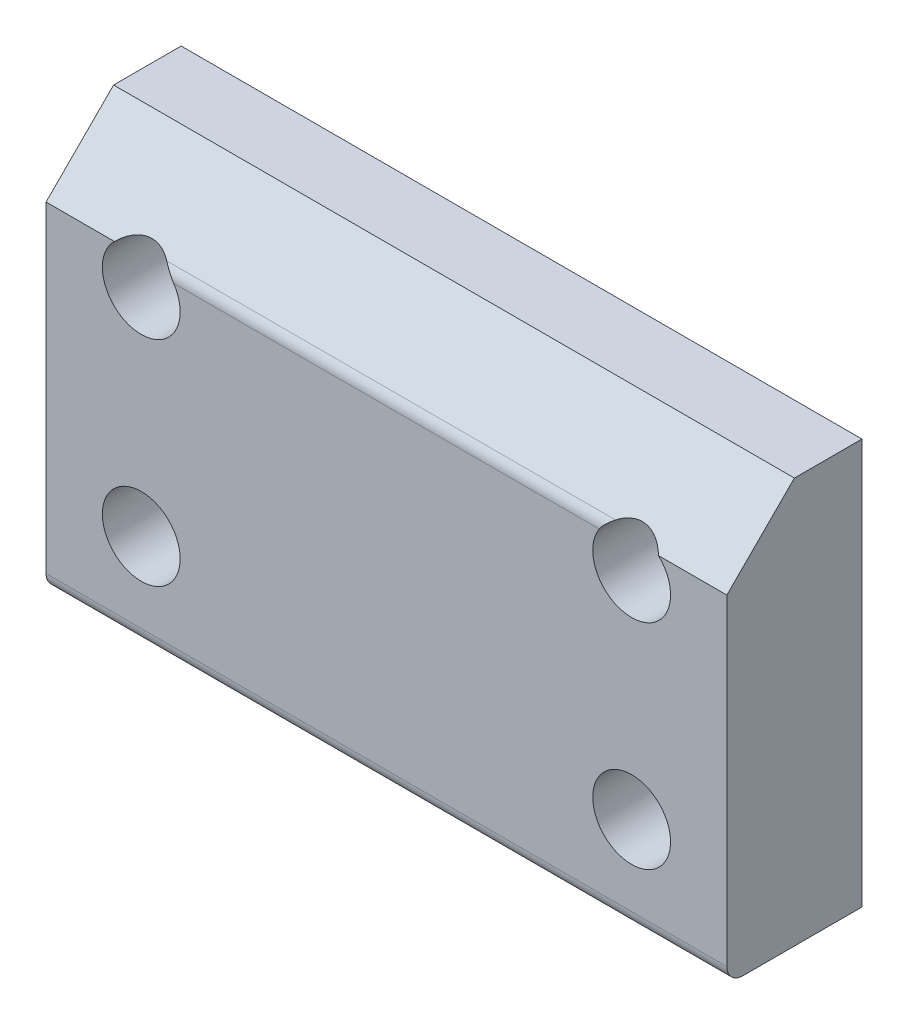
from build123d import *

# Parameters (mm, degrees)
BOSS_EXTRUDE1_DEPTH                            = 16
CBORE_FOR_6_SOCKET_HEAD_CAP_SCREW1_D           = 3.6576
CBORE_FOR_6_SOCKET_HEAD_CAP_SCREW1_DEPTH       = 9.398
CBORE_FOR_6_SOCKET_HEAD_CAP_SCREW1_CBORE_D     = 7.14502
CBORE_FOR_6_SOCKET_HEAD_CAP_SCREW1_CBORE_DEPTH = 2.54
CBORE_FOR_6_SOCKET_HEAD_CAP_SCREW1_TIP         = 1.0988539
FILLET1_R                                      = 0.75


with BuildPart() as part:
    # Sketch1 → Boss-Extrude1 (new, symmetric)
    with BuildSketch(Plane(origin=(0, 0, 0), x_dir=(0, 0, -1), z_dir=(1, 0, 0))):
        Polygon((0, 6.35), (3.175, 9.525), (6.35, 9.525), (6.35, -9.525), (0, -9.525), align=None)
    extrude(amount=BOSS_EXTRUDE1_DEPTH, both=True)

    # CBORE for _6 Socket Head Cap Screw1
    with Locations(Plane(origin=(0, 0, -6.35), x_dir=(-1, 0, 0), z_dir=(0, 0, -1))):
        with Locations((11.525, -5.025), (-11.525, 5.025), (-11.525, -5.025), (11.525, 5.025)):
            CounterBoreHole(CBORE_FOR_6_SOCKET_HEAD_CAP_SCREW1_D / 2, CBORE_FOR_6_SOCKET_HEAD_CAP_SCREW1_CBORE_D / 2, CBORE_FOR_6_SOCKET_HEAD_CAP_SCREW1_CBORE_DEPTH, depth=CBORE_FOR_6_SOCKET_HEAD_CAP_SCREW1_DEPTH)
            with Locations((0, 0, -(CBORE_FOR_6_SOCKET_HEAD_CAP_SCREW1_DEPTH + CBORE_FOR_6_SOCKET_HEAD_CAP_SCREW1_TIP / 2))):  # 118° drill point
                Cone(0, CBORE_FOR_6_SOCKET_HEAD_CAP_SCREW1_D / 2, CBORE_FOR_6_SOCKET_HEAD_CAP_SCREW1_TIP, mode=Mode.SUBTRACT)

    # Fillet1
    fillet1_edges = [part.edges().sort_by_distance(p)[0] for p in [
        (0, 6.35, 0),
        (0, -9.525, 0),
    ]]
    fillet(fillet1_edges, radius=FILLET1_R)


solid = part.part
